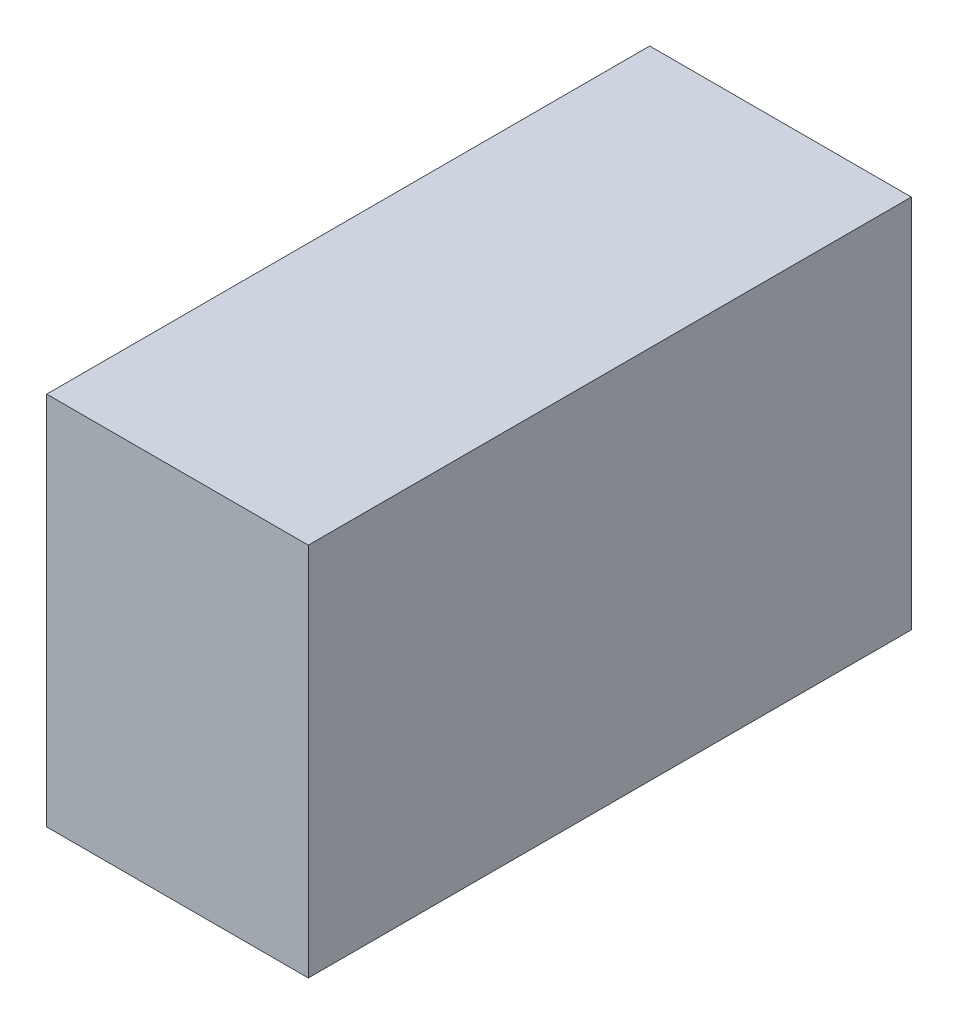
from build123d import *

# Parameters (mm, degrees)
SKETCH1_W           = 65.6
SKETCH1_H           = 151.2
BOSS_EXTRUDE1_DEPTH = 94


with BuildPart() as part:
    # Sketch1 → Boss-Extrude1 (new body)
    with BuildSketch(Plane(origin=(0, 0, 0), x_dir=(1, 0, 0), z_dir=(0, 1, 0))):
        Rectangle(SKETCH1_W, SKETCH1_H)
    extrude(amount=BOSS_EXTRUDE1_DEPTH)


solid = part.part
